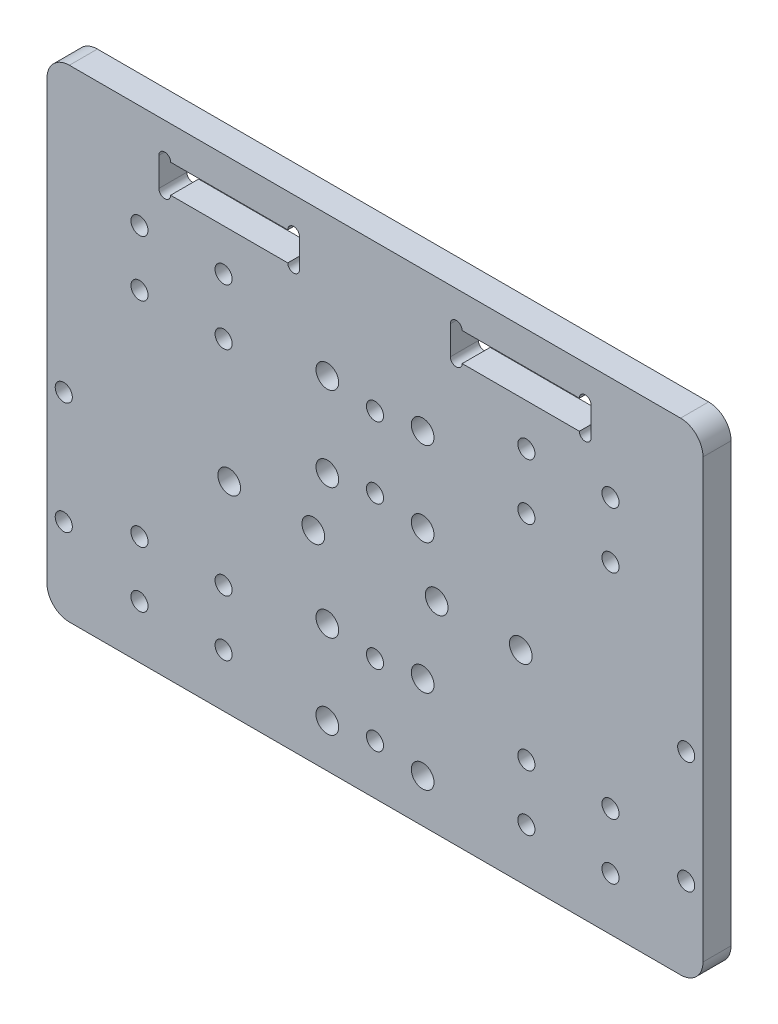
from build123d import *

# Parameters (mm, degrees)
SKETCH_1_W          = 117
SKETCH_1_H          = 80
EXTRUDE_1_DEPTH     = 5
SKETCH_2_R          = 1.525
CUT_EXTRUDE_1_DEPTH = 5
SKETCH_3_R          = 2.025
CUT_EXTRUDE_2_DEPTH = 5
SKETCH_4_R          = 2.025
CUT_EXTRUDE_3_DEPTH = 5
SKETCH_5_R          = 1.525
CUT_EXTRUDE_4_DEPTH = 5
SKETCH_6_R          = 1.525
CUT_EXTRUDE_5_DEPTH = 5
SKETCH_7_R          = 2.024999998
CUT_EXTRUDE_6_DEPTH = 5
SKETCH_9_W          = 117
SKETCH_9_H          = 6
EXTRUDE_2_DEPTH     = 5
FILLET_2_R          = 4
SKETCH_10_W         = 2.1
SKETCH_10_H         = 5.1
SKETCH_10_W_2       = 20.9
CUT_EXTRUDE_7_DEPTH = 5


with BuildPart() as part:
    # 草图1 → 凸台-拉伸1 (new body)
    with BuildSketch(Plane.XY):
        Rectangle(SKETCH_1_W, SKETCH_1_H)
    extrude(amount=EXTRUDE_1_DEPTH)

    # 草图2 → 切除-拉伸1 (cut)
    with BuildSketch(Plane.XY.offset(5)):
        with Locations((-27, -20.55)):
            Circle(SKETCH_2_R)
        with Locations((-42, -20.55)):
            Circle(SKETCH_2_R)
        with Locations((-42, -30.55)):
            Circle(SKETCH_2_R)
        with Locations((-27, -30.55)):
            Circle(SKETCH_2_R)
        with Locations((-42, 27.5)):
            Circle(SKETCH_2_R)
        with Locations((-42, 17.5)):
            Circle(SKETCH_2_R)
        with Locations((-27, 27.5)):
            Circle(SKETCH_2_R)
        with Locations((-27, 17.5)):
            Circle(SKETCH_2_R)
    cut_extrude_1 = extrude(amount=-CUT_EXTRUDE_1_DEPTH, mode=Mode.SUBTRACT)

    # 镜向1: 切除-拉伸1 across plane
    add(cut_extrude_1.mirror(Plane(origin=(0, 0, 0), x_dir=(0, 0, 1), z_dir=(1, 0, 0))), mode=Mode.SUBTRACT)

    # 草图3 → 切除-拉伸2 (cut)
    with BuildSketch(Plane.XY.offset(5)):
        with Locations((-8.5, 21)):
            Circle(SKETCH_3_R)
        with Locations((8.5, 21)):
            Circle(SKETCH_3_R)
        with Locations((8.5, 6)):
            Circle(SKETCH_3_R)
        with Locations((-8.5, 6)):
            Circle(SKETCH_3_R)
    extrude(amount=-CUT_EXTRUDE_2_DEPTH, mode=Mode.SUBTRACT)

    # 草图4 → 切除-拉伸3 (cut)
    with BuildSketch(Plane.XY.offset(5)):
        with Locations((8.5, -17.25)):
            Circle(SKETCH_4_R)
        with Locations((8.5, -32.25)):
            Circle(SKETCH_4_R)
        with Locations((-8.5, -32.25)):
            Circle(SKETCH_4_R)
        with Locations((-8.5, -17.25)):
            Circle(SKETCH_4_R)
    extrude(amount=-CUT_EXTRUDE_3_DEPTH, mode=Mode.SUBTRACT)

    # 草图5 → 切除-拉伸4 (cut)
    with BuildSketch(Plane.XY.offset(5)):
        with Locations((-55.5, -5)):
            Circle(SKETCH_5_R)
        with Locations((-55.5, -25)):
            Circle(SKETCH_5_R)
    cut_extrude_4 = extrude(amount=-CUT_EXTRUDE_4_DEPTH, mode=Mode.SUBTRACT)

    # 镜向2: 切除-拉伸4 across plane
    add(cut_extrude_4.mirror(Plane(origin=(0, 0, 0), x_dir=(0, 0, 1), z_dir=(1, 0, 0))), mode=Mode.SUBTRACT)

    # 草图6 → 切除-拉伸5 (cut)
    with BuildSketch(Plane.XY.offset(5)):
        with Locations((0, 19.85)):
            Circle(SKETCH_6_R)
        with Locations((0, 7.15)):
            Circle(SKETCH_6_R)
        with Locations((0, -18.4)):
            Circle(SKETCH_6_R)
        with Locations((0, -31.1)):
            Circle(SKETCH_6_R)
    extrude(amount=-CUT_EXTRUDE_5_DEPTH, mode=Mode.SUBTRACT)

    # 草图7 → 切除-拉伸6 (cut)
    with BuildSketch(Plane.XY.offset(5)):
        with Locations((26, -4.049999992)):
            Circle(SKETCH_7_R)
        with Locations((11, -4.049999992)):
            Circle(SKETCH_7_R)
    cut_extrude_6 = extrude(amount=-CUT_EXTRUDE_6_DEPTH, mode=Mode.SUBTRACT)

    # 镜向4: 切除-拉伸6 across plane
    add(cut_extrude_6.mirror(Plane(origin=(0, 0, 0), x_dir=(0, 0, 1), z_dir=(1, 0, 0))), mode=Mode.SUBTRACT)

    # 草图9 → 凸台-拉伸2 (add)
    with BuildSketch(Plane.XY.offset(5)):
        with Locations((0, 43)):
            Rectangle(SKETCH_9_W, SKETCH_9_H)
    extrude(amount=-EXTRUDE_2_DEPTH)

    # 圆角2
    fillet_2_edges = [part.edges().sort_by_distance(p)[0] for p in [
        (58.5, 46, 2.5),
        (-58.5, 46, 2.5),
        (58.5, -40, 2.5),
        (-58.5, -40, 2.5),
    ]]
    fillet(fillet_2_edges, radius=FILLET_2_R)

    # 草图10 → 切除-拉伸7 (cut)
    with BuildSketch(Plane.XY.offset(5)):
        with BuildLine():
            ThreePointArc((-36.45, 40.05), (-37.5, 41.1), (-38.55, 40.05))
            Line((-38.55, 40.05), (-36.45, 40.05))
        make_face()
        with Locations((-37.5, 37.5)):
            Rectangle(SKETCH_10_W, SKETCH_10_H)
        with Locations((-26, 37.5)):
            Rectangle(SKETCH_10_W_2, SKETCH_10_H)
        with BuildLine():
            Line((-36.45, 34.95), (-38.55, 34.95))
            ThreePointArc((-38.55, 34.95), (-37.5, 33.9), (-36.45, 34.95))
        make_face()
        with BuildLine():
            ThreePointArc((-13.45, 40.05), (-14.5, 41.1), (-15.55, 40.05))
            Line((-15.55, 40.05), (-13.45, 40.05))
        make_face()
        with Locations((-14.5, 37.5)):
            Rectangle(SKETCH_10_W, SKETCH_10_H)
        with BuildLine():
            Line((-13.45, 34.95), (-15.55, 34.95))
            ThreePointArc((-15.55, 34.95), (-14.5, 33.9), (-13.45, 34.95))
        make_face()
    cut_extrude_7 = extrude(amount=-CUT_EXTRUDE_7_DEPTH, mode=Mode.SUBTRACT)

    # 镜向5: 切除-拉伸7 across plane
    add(cut_extrude_7.mirror(Plane(origin=(0, 0, 0), x_dir=(0, 0, 1), z_dir=(1, 0, 0))), mode=Mode.SUBTRACT)


solid = part.part
